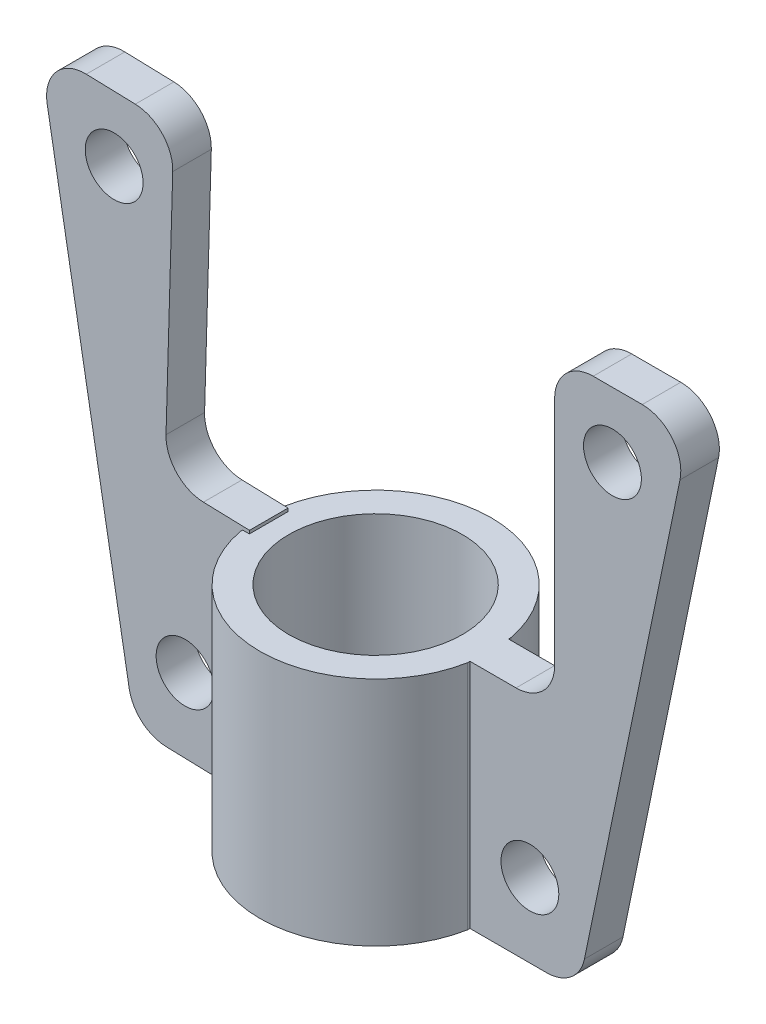
from build123d import *

# Parameters (mm, degrees)
CROQUIS1_R              = 22.5
SALIENTE_EXTRUIR1_DEPTH = 60
CROQUIS2_R              = 7.5
SALIENTE_EXTRUIR2_DEPTH = 5


with BuildPart() as part:
    # Croquis1 → Saliente-Extruir1 (new body)
    with BuildSketch(Plane(origin=(0, 0, 0), x_dir=(1, 0, 0), z_dir=(0, 1, 0))):
        with BuildLine():
            Line((-29.464610793, 5.64240293), (-29.464610793, -5.64240293))
            ThreePointArc((-29.464610793, -5.64240293), (0, -30), (29.464610793, -5.64240293))
            Line((29.464610793, -5.64240293), (29.464610793, 5.64240293))
            ThreePointArc((29.464610793, 5.64240293), (0, 30), (-29.464610793, 5.64240293))
        make_face()
        with Locations(Location((0, 0, 0), (0, 0, 270))):  # turned: the seam where the file's is
            Circle(CROQUIS1_R, mode=Mode.SUBTRACT)
    extrude(amount=SALIENTE_EXTRUIR1_DEPTH)

    # Croquis2 → Saliente-Extruir2 (add, symmetric)
    with BuildSketch(Plane.XY):
        with BuildLine():
            Line((29.464610793, 60), (29.464610793, 0))
            Line((29.464610793, 0), (49.359858197, 0))
            ThreePointArc((49.359858197, 0), (55.675693274, 2.246921433), (59.153291312, 7.977954546))
            Line((59.153291312, 7.977954546), (83.929633957, 127.977954546))
            ThreePointArc((83.929633957, 127.977954546), (81.889279409, 136.315835078), (74.136200842, 140))
            Line((74.136200842, 140), (61.411819936, 140))
            ThreePointArc((61.411819936, 140), (54.340752124, 137.071067812), (51.411819936, 130))
            Line((51.411819936, 130), (51.411819936, 70))
            ThreePointArc((51.411819936, 70), (48.482887748, 62.928932188), (41.411819936, 60))
            Line((41.411819936, 60), (29.464610793, 60))
        make_face()
        with Locations((45, 19.203564165)):
            Circle(CROQUIS2_R, mode=Mode.SUBTRACT)
        with Locations(Location((66.411819936, 123.15179788, 0), (0, 0, 180))):  # turned: the seam where the file's is
            Circle(CROQUIS2_R, mode=Mode.SUBTRACT)
        with BuildLine():
            Line((-39.648553202, 61.179498685), (-27.706402099, 60.831887788))
            Line((-27.706402099, 60.831887788), (-29.452136484, 0.857289737))
            Line((-29.452136484, 0.857289737), (-49.33896092, 1.436153362))
            ThreePointArc((-49.33896092, 1.436153362), (-55.586746623, 3.865886366), (-58.896124671, 9.695675863))
            Line((-58.896124671, 9.695675863), (-80.17050909, 130.365753854))
            ThreePointArc((-80.17050909, 130.365753854), (-77.888422947, 138.640739128), (-70.031433878, 142.097764037))
            Line((-70.031433878, 142.097764037), (-57.31244004, 141.727540882))
            ThreePointArc((-57.31244004, 141.727540882), (-50.329584837, 138.594111934), (-47.607629428, 131.44081881))
            Line((-47.607629428, 131.44081881), (-49.353363814, 71.466220758))
            ThreePointArc((-49.353363814, 71.466220758), (-46.631408405, 64.312927634), (-39.648553202, 61.179498685))
        make_face()
        with Locations((-62.800531307, 125.03194958)):
            Circle(CROQUIS2_R, mode=Mode.SUBTRACT)
        with Locations(Location((-44.422209834, 20.504734822, 0), (0, 0, 180))):  # turned: the seam where the file's is
            Circle(CROQUIS2_R, mode=Mode.SUBTRACT)
    extrude(amount=SALIENTE_EXTRUIR2_DEPTH, both=True)


solid = part.part
